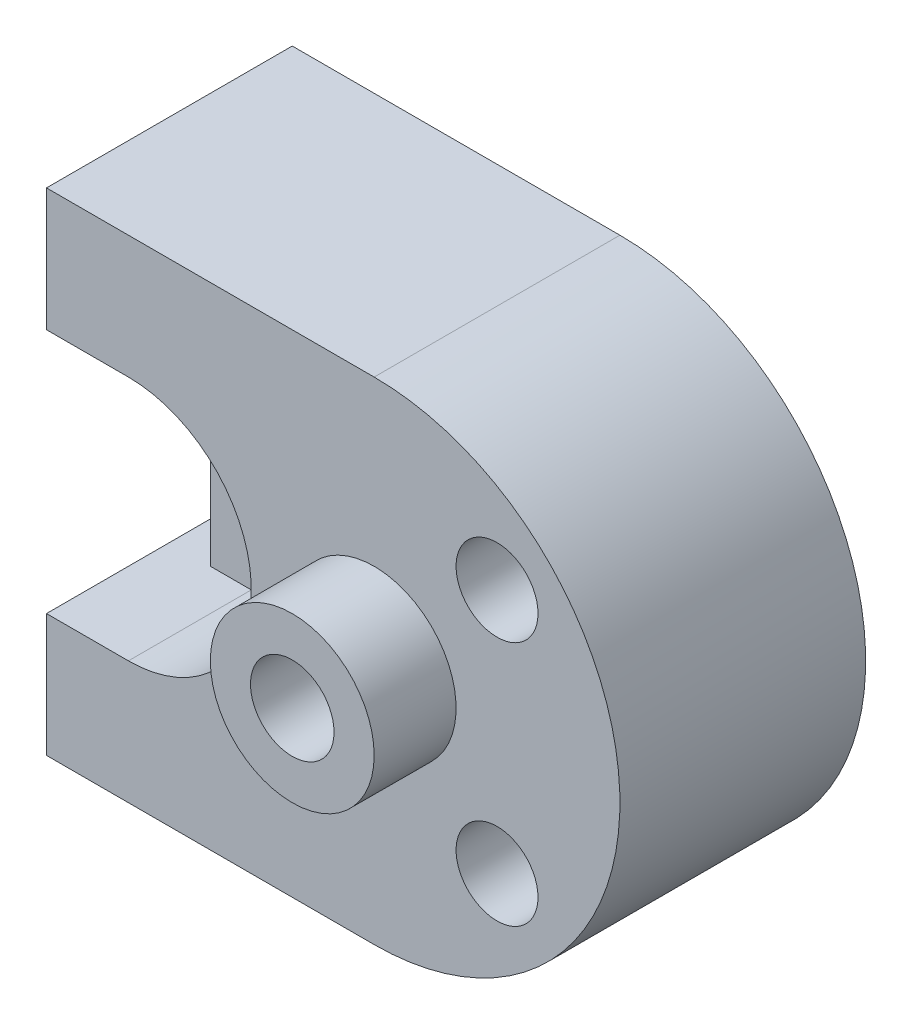
from build123d import *

# Parameters (mm, degrees)
BOSS_EXTRUDE1_DEPTH    = 30
BOSS_EXTRUDE3_DEPTH    = 30
CUT_EXTRUDE1_DEPTH     = 15
SKETCH7_R              = 5
CUT_EXTRUDE2_DEPTH     = 35
SKETCH8_R              = 10
BOSS_EXTRUDE4_DEPTH    = 10
SKETCH10_R             = 5
CUT_EXTRUDE6_DEPTH     = 10
SKETCH12_R             = 2.5
CUT_EXTRUDE7_DEPTH     = 10
SKETCH13_R             = 5
CUT_EXTRUDE8_DEPTH     = 10
M12_TAPPED_HOLE1_D     = 10.2
M12_TAPPED_HOLE1_DEPTH = 15
M12_TAPPED_HOLE1_TIP   = 3.064389157


with BuildPart() as part:
    # Sketch1 → Boss-Extrude1 (new body)
    with BuildSketch(Plane.XY):
        with BuildLine():
            Line((-40, 30), (-40, 15))
            Line((-40, 15), (-30, 15))
            ThreePointArc((-30, 15), (-15, 0), (-30, -15))
            Line((-30, -15), (-40, -15))
            Line((-40, -15), (-40, -30))
            Line((-40, -30), (0, -30))
            ThreePointArc((0, -30), (30, 0), (0, 30))
            Line((0, 30), (-40, 30))
        make_face()
    extrude(amount=BOSS_EXTRUDE1_DEPTH)

    # Sketch5 → Boss-Extrude3 (add)
    with BuildSketch(Plane.XY.offset(30)):
        with BuildLine():
            Line((-30, 15), (-35, 15))
            Line((-35, 15), (-35, -15))
            Line((-35, -15), (-30, -15))
            ThreePointArc((-30, -15), (-15, 0), (-30, 15))
        make_face()
    extrude(amount=-BOSS_EXTRUDE3_DEPTH)

    # Sketch6 → Cut-Extrude1 (cut)
    with BuildSketch(Plane.XY.offset(30)):
        with BuildLine():
            Line((-35, 15), (-30, 15))
            ThreePointArc((-30, 15), (-14.999999991, 0.000506597), (-29.998986771, -15))
            Line((-29.998986771, -15), (-35, -15))
            Line((-35, -15), (-35, 15))
        make_face()
    extrude(amount=-CUT_EXTRUDE1_DEPTH, mode=Mode.SUBTRACT)

    # Sketch7 → Cut-Extrude2 (cut)
    with BuildSketch(Plane.XY.offset(15)):
        with Locations((-25, 0)):
            Circle(SKETCH7_R)
    extrude(amount=-CUT_EXTRUDE2_DEPTH, mode=Mode.SUBTRACT)

    # Sketch8 → Boss-Extrude4 (add)
    with BuildSketch(Plane.XY.offset(30)):
        Circle(SKETCH8_R)
    extrude(amount=BOSS_EXTRUDE4_DEPTH)

    # Sketch10 → Cut-Extrude6 (cut)
    with BuildSketch(Plane.XY.offset(30)):
        with Locations((15, 15)):
            Circle(SKETCH10_R)
        with Locations((15, -15)):
            Circle(SKETCH10_R)
    extrude(amount=-CUT_EXTRUDE6_DEPTH, mode=Mode.SUBTRACT)

    # Sketch12 → Cut-Extrude7 (cut)
    with BuildSketch(Plane.XY.offset(20)):
        with Locations((15, 15)):
            Circle(SKETCH12_R)
        with Locations((15, -15)):
            Circle(SKETCH12_R)
    extrude(amount=-CUT_EXTRUDE7_DEPTH, mode=Mode.SUBTRACT)

    # Sketch13 → Cut-Extrude8 (cut)
    with BuildSketch(Plane(origin=(0, 0, 0), x_dir=(-1, 0, 0), z_dir=(0, 0, -1))):
        with Locations((-15, 15)):
            Circle(SKETCH13_R)
        with Locations((-15, -15)):
            Circle(SKETCH13_R)
    extrude(amount=-CUT_EXTRUDE8_DEPTH, mode=Mode.SUBTRACT)

    # M12 Tapped Hole1
    with Locations(Plane.XY.offset(40)):
        with Locations((0, 0)):
            Hole(M12_TAPPED_HOLE1_D / 2, depth=M12_TAPPED_HOLE1_DEPTH)
            with Locations((0, 0, -(M12_TAPPED_HOLE1_DEPTH + M12_TAPPED_HOLE1_TIP / 2))):  # 118° drill point
                Cone(0, M12_TAPPED_HOLE1_D / 2, M12_TAPPED_HOLE1_TIP, mode=Mode.SUBTRACT)


solid = part.part
